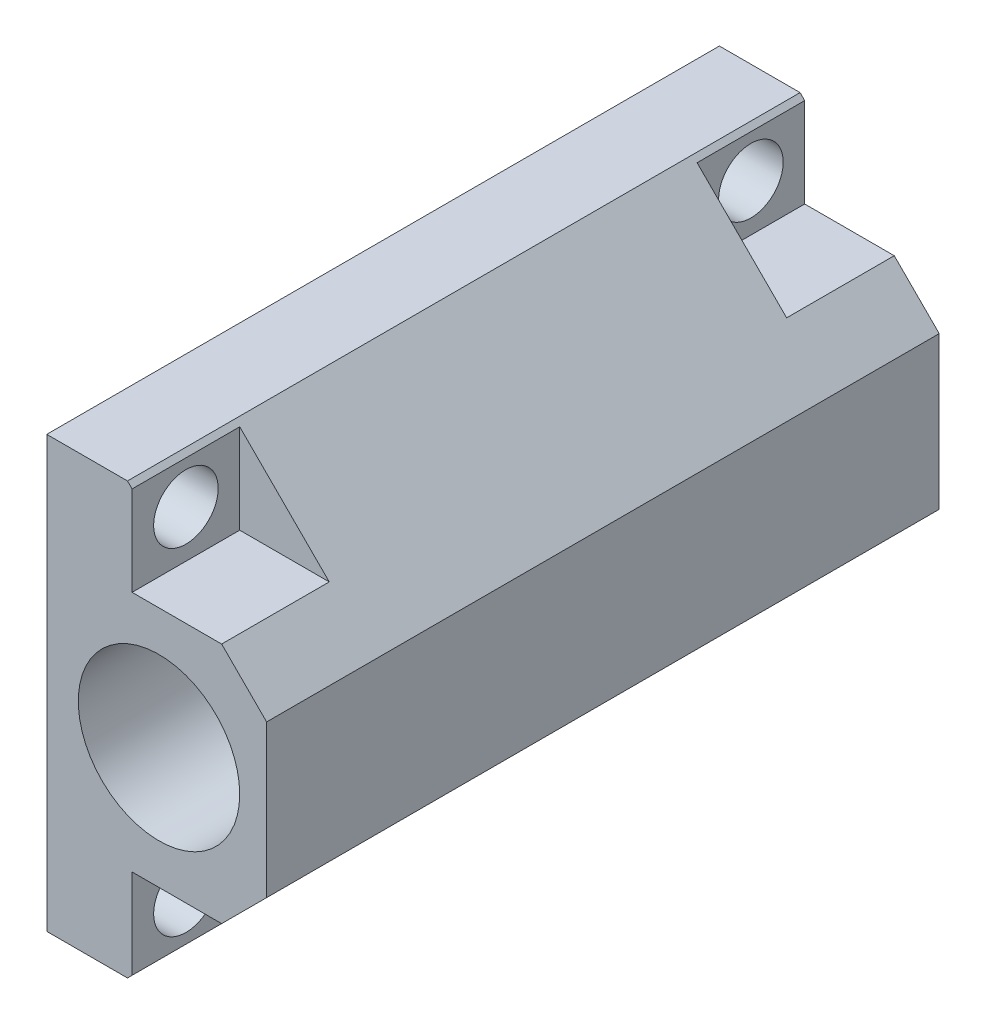
from build123d import *

# Parameters (mm, degrees)
SKETCH1_W            = 3
SKETCH1_H            = 16
BOSS_EXTRUDE1_DEPTH  = 25
BOSS_EXTRUDE2_DEPTH  = 25
M2_CLEARANCE_HOLE1_D = 2.4
CHAMFER1_SIZE        = 4
SKETCH12_W           = 4
SKETCH12_H           = 3.5
SKETCH12_R           = 1.2
CUT_EXTRUDE1_DEPTH   = 5


with BuildPart() as part:
    # Sketch1 → Boss-Extrude1 (new body)
    with BuildSketch(Plane.XY):
        Rectangle(SKETCH1_W, SKETCH1_H)
    extrude(amount=BOSS_EXTRUDE1_DEPTH)

    # Sketch4 → Boss-Extrude2 (add, through all)
    with BuildSketch(Plane.XY.offset(25)):
        Polygon((1.5, 8), (9.5, 0), (1.5, -8), align=None)
    extrude(amount=-BOSS_EXTRUDE2_DEPTH)

    # M2 Clearance Hole1 (through all)
    with Locations(Plane(origin=(-1.5, 0, 0), x_dir=(0, 0, -1), z_dir=(-1, 0, 0))):
        with Locations((-2, -6.25), (-23, 6.25), (-23, -6.25), (-2, 6.25)):
            Hole(M2_CLEARANCE_HOLE1_D / 2)

    # Chamfer1
    chamfer1_edges = [part.edges().sort_by_distance(p)[0] for p in [
        (9.5, 0, 12.5),
    ]]
    chamfer(chamfer1_edges, length=CHAMFER1_SIZE)

    # Sketch8 → Ø6.0mm Dowel Hole3 (revolve, cut)
    with BuildSketch(Plane(origin=(2.671572875, 0, 25), x_dir=(0, -1, 0), z_dir=(1, 0, 0))):
        Polygon((0, 0), (0, 9.802581857), (3, 8), (3, 0), align=None)
    f_6_0mm_dowel_hole3 = revolve(axis=Axis((2.671572875, 0, 31.35), (0, 0, -1)), mode=Mode.SUBTRACT)

    # Mirror2: Ø6.0mm Dowel Hole3 across plane
    add(f_6_0mm_dowel_hole3.mirror(Plane.XY.offset(12.5)), mode=Mode.SUBTRACT)

    # Sketch12 → Cut-Extrude1 (cut)
    with BuildSketch(Plane(origin=(6.671572875, 0, 0), x_dir=(0, 0, -1), z_dir=(1, 0, 0))):
        with Locations((-2, 6.25)):
            Rectangle(SKETCH12_W, SKETCH12_H)
        with Locations((-2, 6.25)):
            Circle(SKETCH12_R, mode=Mode.SUBTRACT)
        with Locations((-2, 6.25)):
            Circle(SKETCH12_R)
        with Locations((-2, -6.25)):
            Circle(SKETCH12_R)
        with Locations((-2, -6.25)):
            Rectangle(SKETCH12_W, SKETCH12_H)
        with Locations((-2, -6.25)):
            Circle(SKETCH12_R, mode=Mode.SUBTRACT)
        with Locations((-23, -6.25)):
            Circle(SKETCH12_R)
        with Locations((-23, -6.25)):
            Rectangle(SKETCH12_W, SKETCH12_H)
        with Locations((-23, -6.25)):
            Circle(SKETCH12_R, mode=Mode.SUBTRACT)
        with Locations((-23, 6.25)):
            Circle(SKETCH12_R)
        with Locations((-23, 6.25)):
            Rectangle(SKETCH12_W, SKETCH12_H)
        with Locations((-23, 6.25)):
            Circle(SKETCH12_R, mode=Mode.SUBTRACT)
    extrude(amount=-CUT_EXTRUDE1_DEPTH, mode=Mode.SUBTRACT)


solid = part.part
